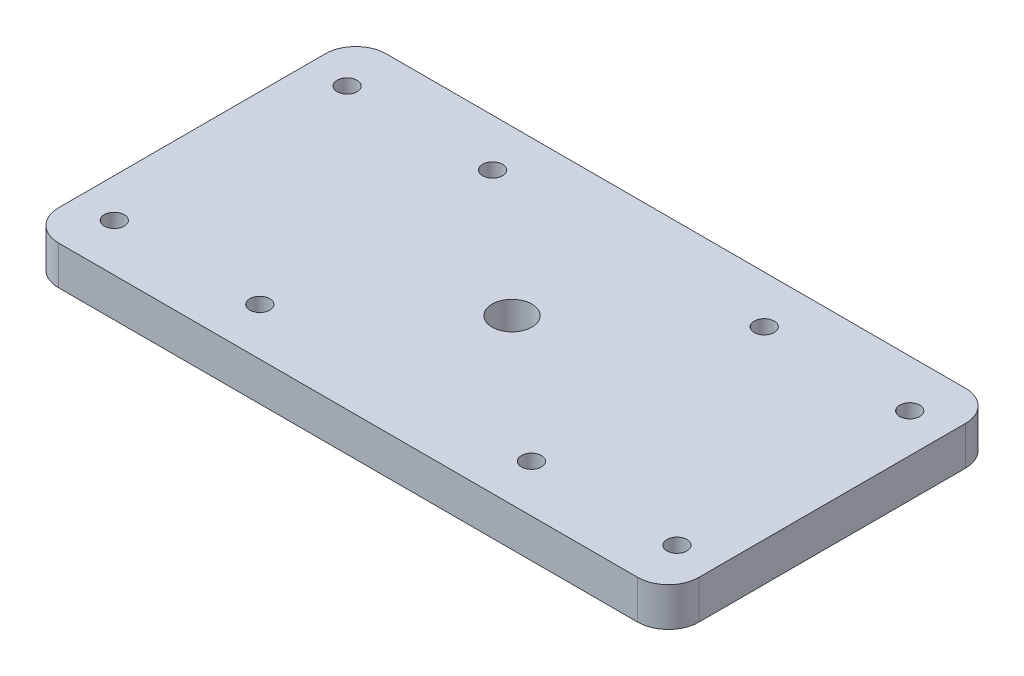
from build123d import *

# Parameters (mm, degrees)
SKETCH1_W                    = 104.78
SKETCH1_H                    = 53.63
BOSS_EXTRUDE1_DEPTH          = 6.35
F_30_0_1285_DIAMETER_HOLE1_D = 3.2639
F_0_257_DIAMETER_HOLE1_D     = 6.5278
FILLET1_R                    = 5


with BuildPart() as part:
    # Sketch1 → Boss-Extrude1 (new body)
    with BuildSketch(Plane(origin=(0, 0, 0), x_dir=(1, 0, 0), z_dir=(0, 1, 0))):
        with Locations((52.39, 26.815)):
            Rectangle(SKETCH1_W, SKETCH1_H)
    extrude(amount=BOSS_EXTRUDE1_DEPTH)

    # #30 (0.1285) Diameter Hole1 (through all)
    with Locations(Plane(origin=(0, 0, 0), x_dir=(-1, 0, 0), z_dir=(0, -1, 0))):
        with Locations((-98.43, 7.765), (-98.43, 45.865), (-74.6175, 7.765), (-74.6175, 45.865), (-30.1675, 7.765), (-30.1675, 45.865), (-6.355, 7.765), (-6.355, 45.865)):
            Hole(F_30_0_1285_DIAMETER_HOLE1_D / 2)

    # F (0.257) Diameter Hole1 (through all)
    with Locations(Plane(origin=(0, 0, 0), x_dir=(-1, 0, 0), z_dir=(0, -1, 0))):
        with Locations((-52.39, 26.815)):
            Hole(F_0_257_DIAMETER_HOLE1_D / 2)

    # Fillet1
    fillet1_edges = [part.edges().sort_by_distance(p)[0] for p in [
        (0, 3.175, -53.63),
        (104.78, 3.175, -53.63),
        (104.78, 3.175, 0),
        (0, 3.175, 0),
    ]]
    fillet(fillet1_edges, radius=FILLET1_R)


solid = part.part
